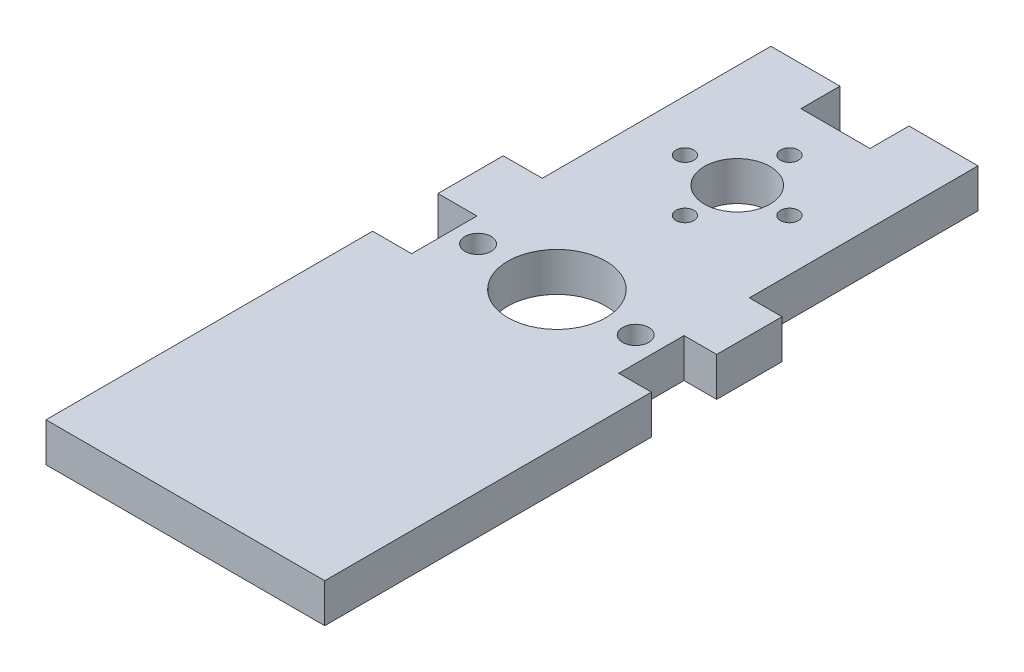
from build123d import *

# Parameters (mm, degrees)
SKETCH1_R           = 5.015
SKETCH1_R_2         = 7.5
SKETCH1_R_3         = 2
SKETCH1_R_4         = 1.37
BOSS_EXTRUDE1_DEPTH = 5.969
SKETCH2_W           = 5.969
SKETCH2_H           = 10
SKETCH2_W_2         = 5
BOSS_EXTRUDE2_DEPTH = 5.969
SKETCH3_W           = 42.669
SKETCH3_H           = 40
BOSS_EXTRUDE3_DEPTH = 5.969


with BuildPart() as part:
    # Sketch1 → Boss-Extrude1 (new body)
    with BuildSketch(Plane(origin=(0, 0, 0), x_dir=(1, 0, 0), z_dir=(0, 1, 0))):
        Polygon((0, 0), (31.7, 0), (31.7, 65), (21.133333333, 65), (21.133333333, 59.031), (10.566666667, 59.031), (10.566666667, 65), (0, 65), align=None)
        with Locations((15.85, 43.99)):
            Circle(SKETCH1_R, mode=Mode.SUBTRACT)
        with Locations((15.85, 16.3861)):
            Circle(SKETCH1_R_2, mode=Mode.SUBTRACT)
        with Locations((3.785, 16.3861)):
            Circle(SKETCH1_R_3, mode=Mode.SUBTRACT)
        with Locations((27.915, 16.3861)):
            Circle(SKETCH1_R_3, mode=Mode.SUBTRACT)
        with Locations((7.85, 43.99)):
            Circle(SKETCH1_R_4, mode=Mode.SUBTRACT)
        with Locations((23.85, 43.99)):
            Circle(SKETCH1_R_4, mode=Mode.SUBTRACT)
        with Locations((15.85, 51.99)):
            Circle(SKETCH1_R_4, mode=Mode.SUBTRACT)
        with Locations((15.85, 35.99)):
            Circle(SKETCH1_R_4, mode=Mode.SUBTRACT)
    extrude(amount=BOSS_EXTRUDE1_DEPTH)

    # Sketch2 → Boss-Extrude2 (add)
    with BuildSketch(Plane(origin=(0, 5.969, 0), x_dir=(1, 0, 0), z_dir=(0, 1, 0))):
        with Locations((-2.9845, 5)):
            Rectangle(SKETCH2_W, SKETCH2_H)
        with Locations((-2.9845, 25)):
            Rectangle(SKETCH2_W, SKETCH2_H)
        with Locations((34.2, 25)):
            Rectangle(SKETCH2_W_2, SKETCH2_H)
        with Locations((34.2, 5)):
            Rectangle(SKETCH2_W_2, SKETCH2_H)
    extrude(amount=-BOSS_EXTRUDE2_DEPTH)

    # Sketch3 → Boss-Extrude3 (add)
    with BuildSketch(Plane(origin=(0, 5.969, 0), x_dir=(1, 0, 0), z_dir=(0, 1, 0))):
        with Locations((15.3655, -20)):
            Rectangle(SKETCH3_W, SKETCH3_H)
    extrude(amount=-BOSS_EXTRUDE3_DEPTH)


solid = part.part
